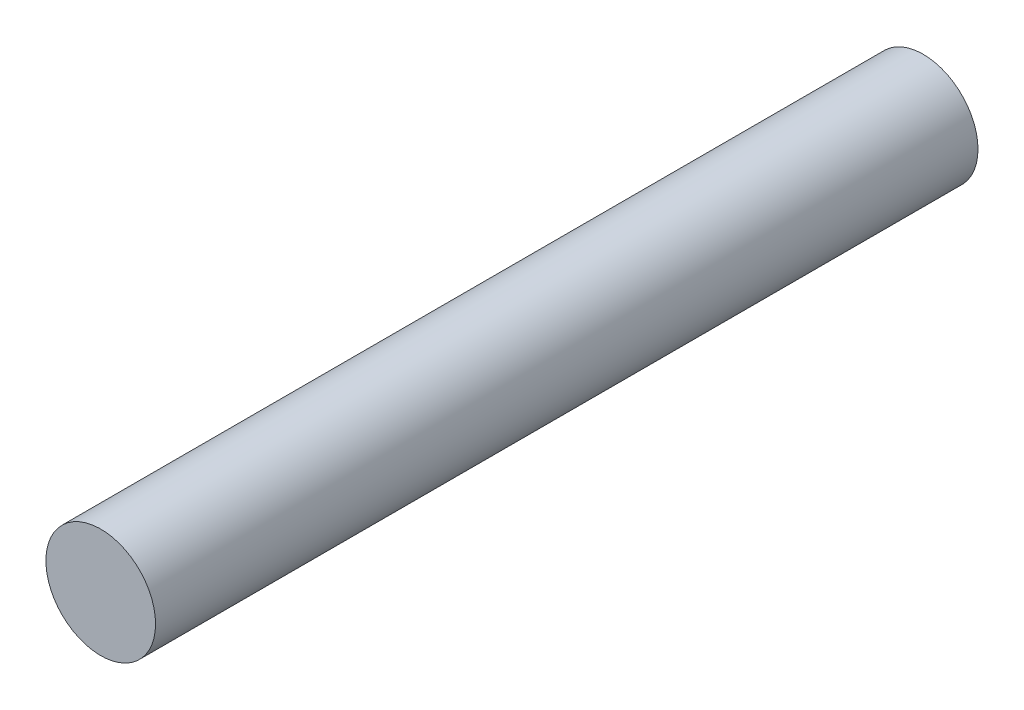
from build123d import *

# Parameters (mm, degrees)
SKETCH1_R      = 2.54
EXTRUDE1_DEPTH = 38.1


with BuildPart() as part:
    # Sketch1 → Extrude1 (new body)
    with BuildSketch(Plane.XY):
        Circle(SKETCH1_R)
    extrude(amount=EXTRUDE1_DEPTH)


solid = part.part
